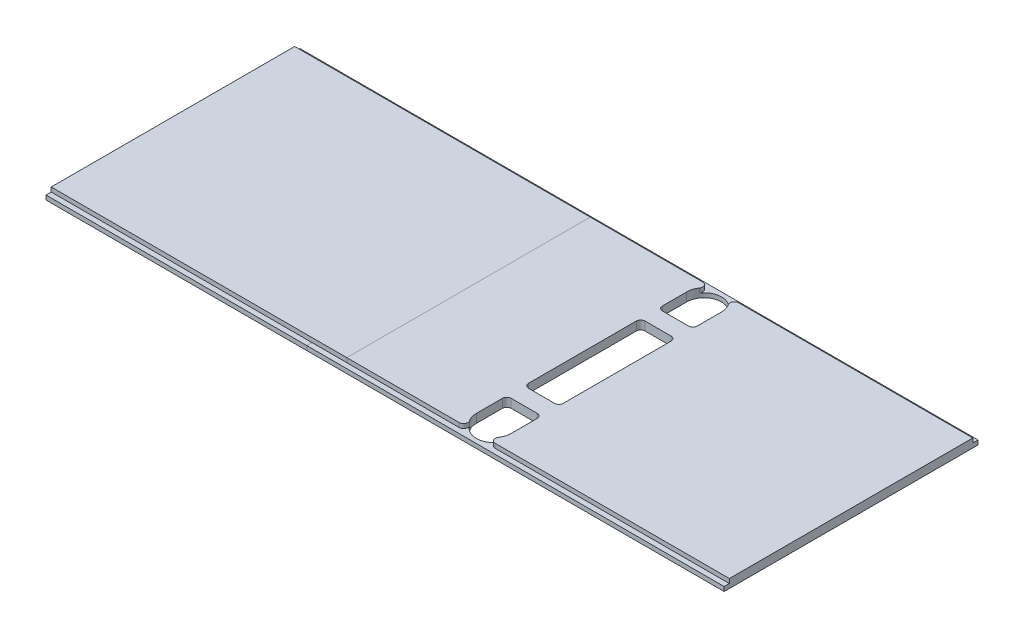
from build123d import *

# Parameters (mm, degrees)
BOSS_EXTRUDE4_DEPTH   = 5
BOSS_EXTRUDE4_2_DEPTH = 5
BOSS_EXTRUDE5_DEPTH   = 2.5
SKETCH18_W            = 20.000000000060737
SKETCH18_H            = 9.999999999999986
BOSS_EXTRUDE6_DEPTH   = 5
FILLET4_R             = 2.5
FILLET5_R             = 2.5
BOSS_EXTRUDE7_DEPTH   = 5
CUT_EXTRUDE1_DEPTH    = 140.00000000000003
SKETCH16_7_W          = 150.00000000000003
SKETCH16_7_H          = 2.999999999999961
SKETCH16_7_W_2        = 150
SKETCH16_7_H_2        = 3
BOSS_EXTRUDE8_DEPTH   = 2.5


with BuildPart() as part:
    # Sketch16 → Boss-Extrude4 (new body)
    with BuildSketch(Plane(origin=(0, 0, 0), x_dir=(1, 0, 0), z_dir=(0, 1, 0))):
        with BuildLine():
            Line((61.87750100080055, -3.0000000000000027), (-9.999999999999972, -3.0000000000000027))
            Line((-9.99999999999998, -3), (-9.99999999999998, -143.00000000000003))
            Line((-9.999999999999972, -143.00000000000003), (61.87750100080078, -143.00000000000003))
            ThreePointArc((61.877501000800784, -142.99999999999997), (56.89984598936563, -139.36408603313456), (54.99999999999999, -133.49999999999997))
            Line((55, -133.49999999999997), (54.99999999999999, -12.5))
            ThreePointArc((54.99999999999999, -12.5), (56.89984598936555, -6.635913966865517), (61.87750100080056, -3.000000000000062))
        make_face()
    extrude(amount=BOSS_EXTRUDE4_DEPTH)



with BuildPart() as body_2:
    # Sketch16 → Boss-Extrude4 2 (new body)
    with BuildSketch(Plane(origin=(0, 0, 0), x_dir=(1, 0, 0), z_dir=(0, 1, 0))):
        with BuildLine():
            Line((209.99999999999991, -143.00000000000003), (209.99999999999991, -3.0000000000000027))
            Line((209.99999999999991, -3.0000000000000027), (68.12249899919945, -3.0000000000000027))
            ThreePointArc((68.12249899919944, -3.000000000000064), (73.10015401063445, -6.635913966865518), (75.00000000000001, -12.500000000000002))
            Line((75.00000000000001, -12.5), (75.00000000000001, -133.49999999999997))
            ThreePointArc((75, -133.49999999999997), (73.10015401063437, -139.36408603313456), (68.12249899919921, -142.99999999999997))
            Line((68.12249899919922, -143.00000000000003), (209.99999999999991, -143.00000000000003))
        make_face()
    extrude(amount=BOSS_EXTRUDE4_2_DEPTH)


with BuildPart() as part_1:
    add(part.part)

    add(body_2.part)  # Boss-Extrude5 merges body 2
    # Sketch16_5 → Boss-Extrude5 (add)
    with BuildSketch(Plane(origin=(0, 0, 0), x_dir=(1, 0, 0), z_dir=(0, 1, 0))):
        with BuildLine():
            Line((-29.99999999999998, 0), (-29.99999999999998, -146))
            Line((-29.99999999999998, -146), (209.99999999999991, -146.00000000000003))
            Line((209.99999999999991, -146.00000000000003), (209.99999999999991, -143.00000000000003))
            Line((209.99999999999991, -143.00000000000003), (68.12249899919922, -143.00000000000003))
            ThreePointArc((68.12249899919921, -142.99999999999997), (65, -143.49999999999997), (61.877501000800784, -142.99999999999997))
            Line((61.87750100080078, -143.00000000000003), (-9.999999999999972, -143.00000000000003))
            Line((-9.99999999999998, -143.00000000000003), (-9.99999999999998, -3))
            Line((-9.999999999999972, -3.0000000000000027), (61.87750100080055, -3.0000000000000027))
            ThreePointArc((61.87750100080056, -3.000000000000062), (65, -2.499999999999984), (68.12249899919944, -3.000000000000064))
            Line((68.12249899919945, -3.0000000000000027), (209.99999999999991, -3.0000000000000027))
            Line((209.99999999999991, -3.0000000000000027), (209.99999999999991, -4.161e-14))
            Line((209.99999999999991, -4.161e-14), (-29.99999999999997, 0))
        make_face()
    extrude(amount=BOSS_EXTRUDE5_DEPTH)

    # Sketch18 → Boss-Extrude6 (add)
    with BuildSketch(Plane.XZ):
        with Locations((65.00000000000001, 111.00000000000003)):
            Rectangle(SKETCH18_W, SKETCH18_H)
        Polygon((75.00000000003038, 39.00000000000002), (54.99999999996964, 39.00000000000002), (54.99999999996964, 29.000000000000025), (75.00000000003038, 29.000000000000018), align=None)
    extrude(amount=-BOSS_EXTRUDE6_DEPTH)

    # Fillet4
    fillet4_edges = [part_1.edges().sort_by_distance(p)[0] for p in [
        (75.00000000003038, 2.5, 116.00000000000001),
        (54.99999999996964, 2.5, 116.00000000000001),
        (75.00000000003038, 2.5, 39.00000000000002),
        (54.99999999996964, 2.5, 39.00000000000002),
        (54.99999999996964, 2.5, 106.00000000000003),
        (75.00000000003038, 2.5, 106.00000000000003),
        (75.00000000003038, 2.5, 29.000000000000018),
        (54.99999999996964, 2.5, 29.000000000000025),
    ]]
    fillet(fillet4_edges, radius=FILLET4_R)

    # Fillet5
    fillet5_edges = [part_1.edges().sort_by_distance(p)[0] for p in [
        (68.12249899919945, 3.75, 3.0000000000000333),
        (61.87750100080055, 3.75, 3.0000000000000333),
        (68.12249899919922, 3.75, 143),
        (61.87750100080078, 3.75, 143),
    ]]
    fillet(fillet5_edges, radius=FILLET5_R)


with BuildPart() as body_2_2:
    # Sketch16_6 → Boss-Extrude7 (new body)
    with BuildSketch(Plane(origin=(0, 0, 0), x_dir=(1, 0, 0), z_dir=(0, 1, 0))):
        Polygon((-180, -3.0000000000000027), (-179.99999999999997, -143.00000000000003), (-9.999999999999972, -143.00000000000003), (-9.99999999999998, -3), align=None)
    extrude(amount=BOSS_EXTRUDE7_DEPTH)

    # Sketch19 → Cut-Extrude1 (cut)
    with BuildSketch(Plane.XY.offset(143.00000000000003)):
        Polygon((-9.99999999999998, 2.5), (-29.999999999999982, 2.4999999999999973), (-29.999999999999982, 0), (-9.99999999999998, 0), align=None)
    extrude(amount=-CUT_EXTRUDE1_DEPTH, mode=Mode.SUBTRACT)

    # Sketch16_7 → Boss-Extrude8 (add)
    with BuildSketch(Plane(origin=(0, 0, 0), x_dir=(1, 0, 0), z_dir=(0, 1, 0))):
        with Locations((-104.99999999999999, -1.5000000000000222)):
            Rectangle(SKETCH16_7_W, SKETCH16_7_H)
        with Locations((-104.99999999999997, -144.50000000000003)):
            Rectangle(SKETCH16_7_W_2, SKETCH16_7_H_2)
    extrude(amount=BOSS_EXTRUDE8_DEPTH)


solid = Compound([part_1.part, body_2_2.part])
